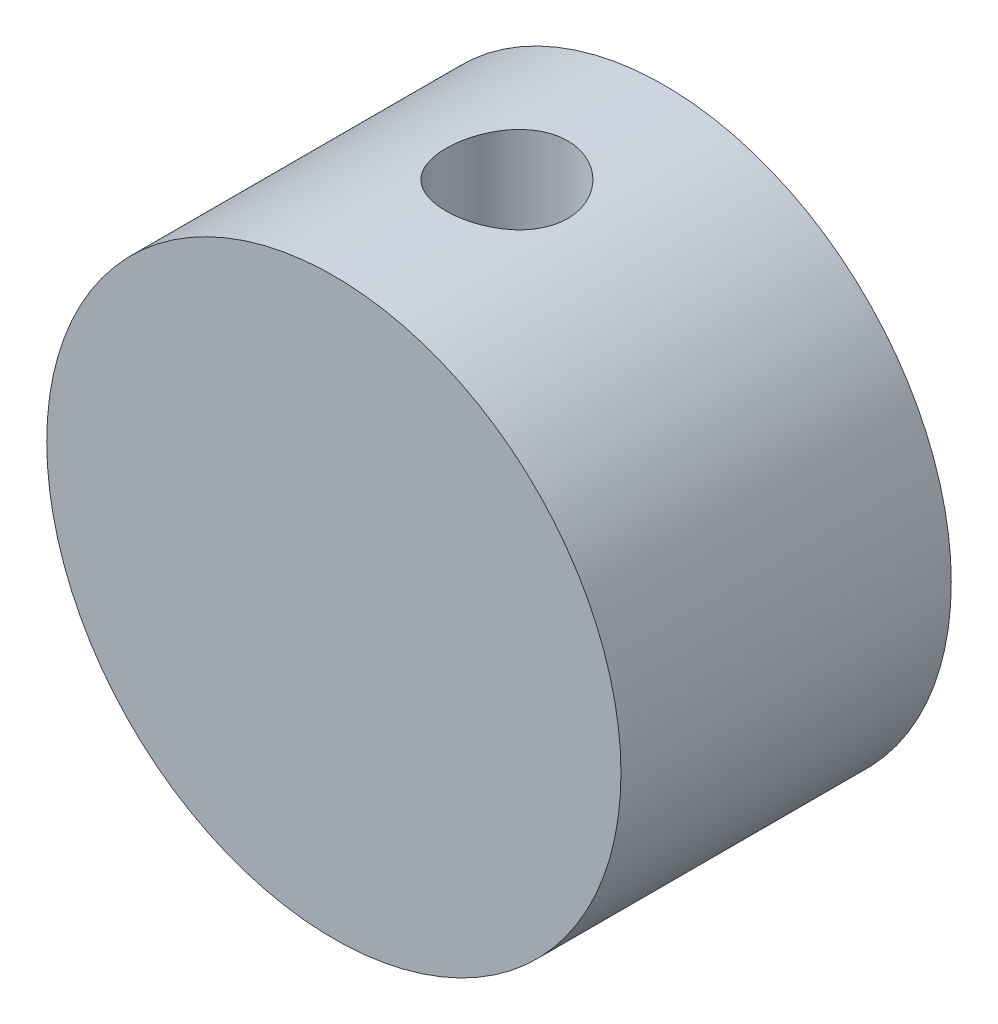
from build123d import *

# Parameters (mm, degrees)
SKETCH1_R           = 16.515
BOSS_EXTRUDE1_DEPTH = 19
SKETCH2_R           = 3.5
CUT_EXTRUDE1_DEPTH  = 31.107979839
SKETCH4_R           = 1
CUT_EXTRUDE2_DEPTH  = 19


with BuildPart() as part:
    # Sketch1 → Boss-Extrude1 (new body)
    with BuildSketch(Plane.XY):
        Circle(SKETCH1_R)
    extrude(amount=BOSS_EXTRUDE1_DEPTH)

    # Sketch2 → Cut-Extrude1 (cut, through all)
    with BuildSketch(Plane(origin=(0, 0, 0), x_dir=(1, 0, 0), z_dir=(0, 1, 0))):
        with Locations((0, -9.045224282)):
            Circle(SKETCH2_R)
    extrude(amount=CUT_EXTRUDE1_DEPTH, mode=Mode.SUBTRACT)

    # Sketch4 → Cut-Extrude2 (cut)
    with BuildSketch(Plane(origin=(-17.320508076, 10, 0), x_dir=(0, 0, 1), z_dir=(-0.86602540378444, 0.49999999999999784, 0))):
        with Locations((9.5, 0)):
            Circle(SKETCH4_R)
    extrude(amount=-CUT_EXTRUDE2_DEPTH, mode=Mode.SUBTRACT)


solid = part.part
